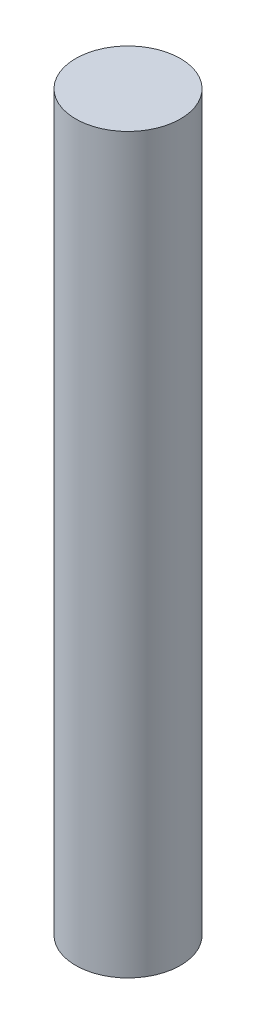
from build123d import *

# Parameters (mm, degrees)
SKETCH1_W = 1.5
SKETCH1_H = 21


with BuildPart() as part:
    # Sketch1 → Revolve1 (revolve)
    with BuildSketch(Plane.XY):
        with Locations((0.75, 10.5)):
            Rectangle(SKETCH1_W, SKETCH1_H)
    revolve(axis=Axis((0, 0, 0), (0, 1, 0)))


solid = part.part
